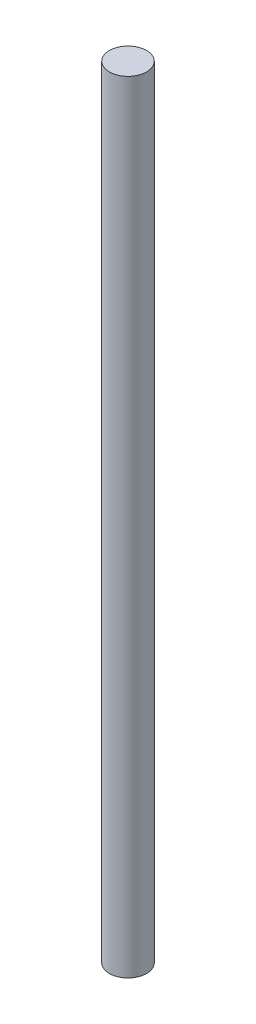
from build123d import *

# Parameters (mm, degrees)
SKETCH1_R           = 1.5
BOSS_EXTRUDE1_DEPTH = 63


with BuildPart() as part:
    # Sketch1 → Boss-Extrude1 (new body)
    with BuildSketch(Plane(origin=(0, 0, 0), x_dir=(1, 0, 0), z_dir=(0, 1, 0))):
        Circle(SKETCH1_R)
    extrude(amount=BOSS_EXTRUDE1_DEPTH)


solid = part.part
